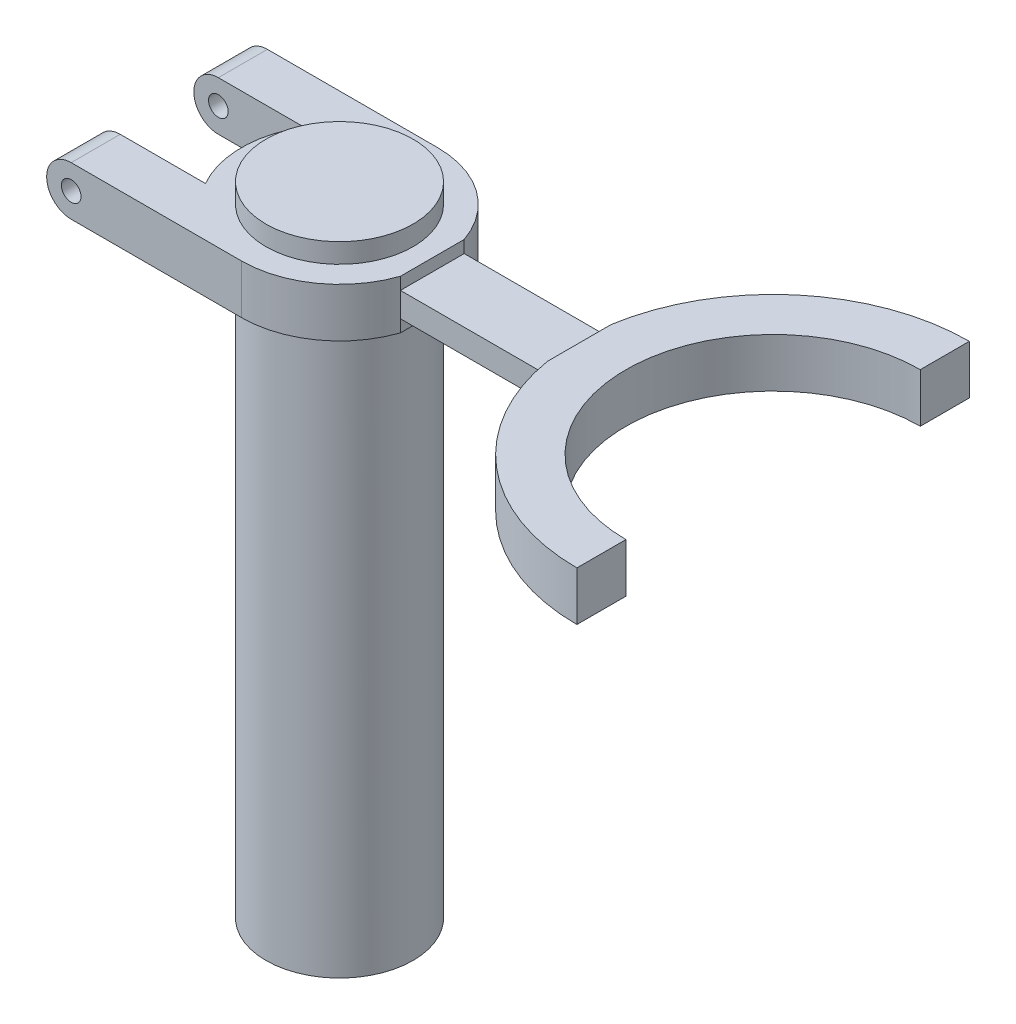
from build123d import *

# Parameters (mm, degrees)
SKETCH2_R               = 15
BOSS_EXTRUDE3_DEPTH     = 10
CUT_EXTRUDE2_DEPTH      = 108.291602107
CUT_EXTRUDE2_DEPTH_BACK = 108.291602107
SKETCH4_R               = 2
SKETCH2_6_R             = 15
BOSS_EXTRUDE5_DEPTH     = 14
BOSS_EXTRUDE6_START     = 116
SKETCH5_R               = 15
BOSS_EXTRUDE6_DEPTH     = 116
CUT_EXTRUDE3_DEPTH      = 154.067755856
CUT_EXTRUDE3_DEPTH_BACK = 154.067755856
SKETCH6_W               = 30
SKETCH6_H               = 2.5


with BuildPart() as part:
    # Sketch2 → Boss-Extrude3 (new body)
    with BuildSketch(Plane(origin=(0, 0, 0), x_dir=(1, 0, 0), z_dir=(0, 1, 0))):
        with BuildLine():
            Line((88.382622063, 30), (88.382622063, 40))
            ThreePointArc((88.382622063, 40), (62.498263852, 30.495901364), (48.914280319, 6.5))
            Line((48.914280319, 6.5), (18.914280319, 6.5))
            ThreePointArc((18.914280319, 6.5), (11.618950039, 16.278820596), (0, 20))
            Line((0, 20), (-39.7, 20))
            Line((-39.7, 20), (-39.7, 10))
            Line((-39.7, 10), (-17.320508076, 10))
            ThreePointArc((-17.320508076, 10), (-20, 0), (-17.320508076, -10))
            Line((-17.320508076, -10), (-39.7, -10))
            Line((-39.7, -10), (-39.7, -20))
            Line((-39.7, -20), (0, -20))
            ThreePointArc((0, -20), (11.618950039, -16.278820596), (18.914280319, -6.5))
            Line((18.914280319, -6.5), (48.914280319, -6.5))
            ThreePointArc((48.914280319, -6.5), (62.498263852, -30.495901364), (88.382622063, -40))
            Line((88.382622063, -40), (88.382622063, -30))
            ThreePointArc((88.382622063, -30), (58.382622063, 0), (88.382622063, 30))
        make_face()
        Circle(SKETCH2_R, mode=Mode.SUBTRACT)
    extrude(amount=BOSS_EXTRUDE3_DEPTH)

    # Sketch4 → Cut-Extrude2 (cut, two sides: drawn at the far end of the back side and taken through both)
    with BuildSketch(Plane.XY.offset(20).offset(-CUT_EXTRUDE2_DEPTH_BACK)):
        with Locations((-34.7, 5)):
            Circle(SKETCH4_R)
        with BuildLine():
            ThreePointArc((-39.7, 5), (-38.235533906, 8.535533906), (-34.7, 10))
            Line((-34.7, 10), (-39.7, 10))
            Line((-39.7, 10), (-39.7, 5))
        make_face()
        with BuildLine():
            Line((-39.7, 0), (-34.7, 0))
            ThreePointArc((-34.7, 0), (-38.235533906, 1.464466094), (-39.7, 5))
            Line((-39.7, 5), (-39.7, 0))
        make_face()
    extrude(amount=CUT_EXTRUDE2_DEPTH + CUT_EXTRUDE2_DEPTH_BACK, mode=Mode.SUBTRACT)

    # Sketch2_6 → Boss-Extrude5 (add)
    with BuildSketch(Plane(origin=(0, 0, 0), x_dir=(1, 0, 0), z_dir=(0, 1, 0))):
        Circle(SKETCH2_6_R)
    extrude(amount=BOSS_EXTRUDE5_DEPTH)

    # Sketch5 → Boss-Extrude6 (add)
    with BuildSketch(Plane.XZ.offset(BOSS_EXTRUDE6_START)):
        Circle(SKETCH5_R)
    extrude(amount=-BOSS_EXTRUDE6_DEPTH)

    # Sketch6 → Cut-Extrude3 (cut, two sides: drawn at the far end of the back side and taken through both)
    with BuildSketch(Plane.XY.offset(6.5).offset(-CUT_EXTRUDE3_DEPTH_BACK)):
        with Locations((33.914280319, 8.75)):
            Rectangle(SKETCH6_W, SKETCH6_H)
        with Locations((33.914280319, 1.25)):
            Rectangle(SKETCH6_W, SKETCH6_H)
    extrude(amount=CUT_EXTRUDE3_DEPTH + CUT_EXTRUDE3_DEPTH_BACK, mode=Mode.SUBTRACT)


solid = part.part
